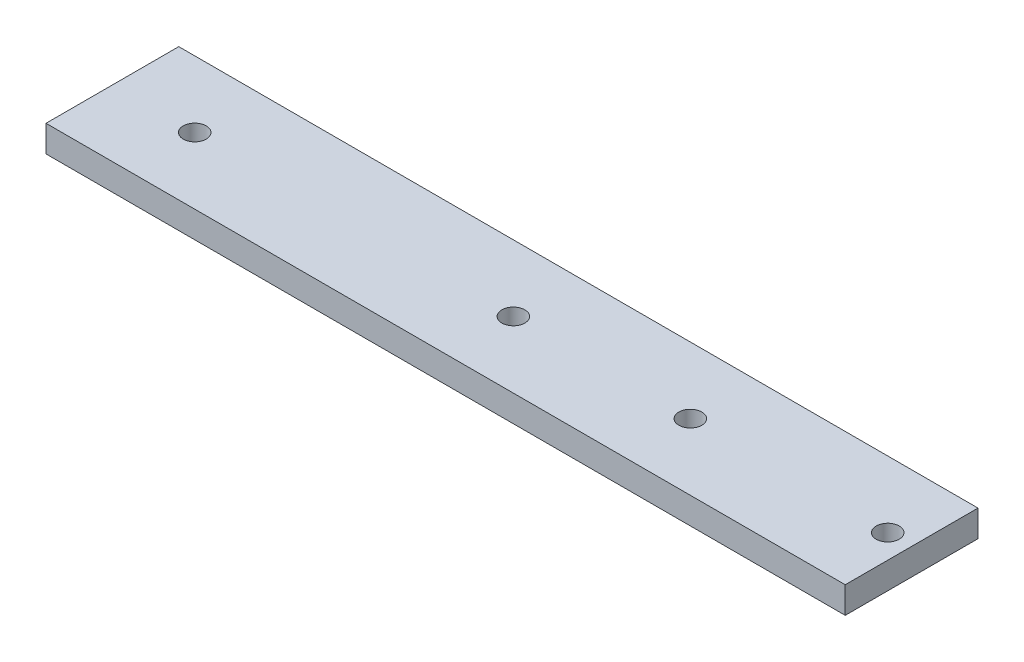
from build123d import *

# Parameters (mm, degrees)
SKETCH_1_R      = 1.3
EXTRUDE_1_DEPTH = 3


with BuildPart() as part:
    # 草图1 → 凸台-拉伸1 (new body)
    with BuildSketch(Plane(origin=(0, 0, 0), x_dir=(1, 0, 0), z_dir=(0, 1, 0))):
        Polygon((-65.303381521, 7.5), (-65.303381521, -7.5), (-56, -7.5), (-20, -7.5), (0, -7.5), (25, -7.5), (25, 0), (25, 7.5), (0, 7.5), align=None)
        with Locations((-56, 0)):
            Circle(SKETCH_1_R, mode=Mode.SUBTRACT)
        with Locations((-20, 0)):
            Circle(SKETCH_1_R, mode=Mode.SUBTRACT)
        Circle(SKETCH_1_R, mode=Mode.SUBTRACT)
        with Locations((22.3, 0)):
            Circle(SKETCH_1_R, mode=Mode.SUBTRACT)
    extrude(amount=EXTRUDE_1_DEPTH)


solid = part.part
